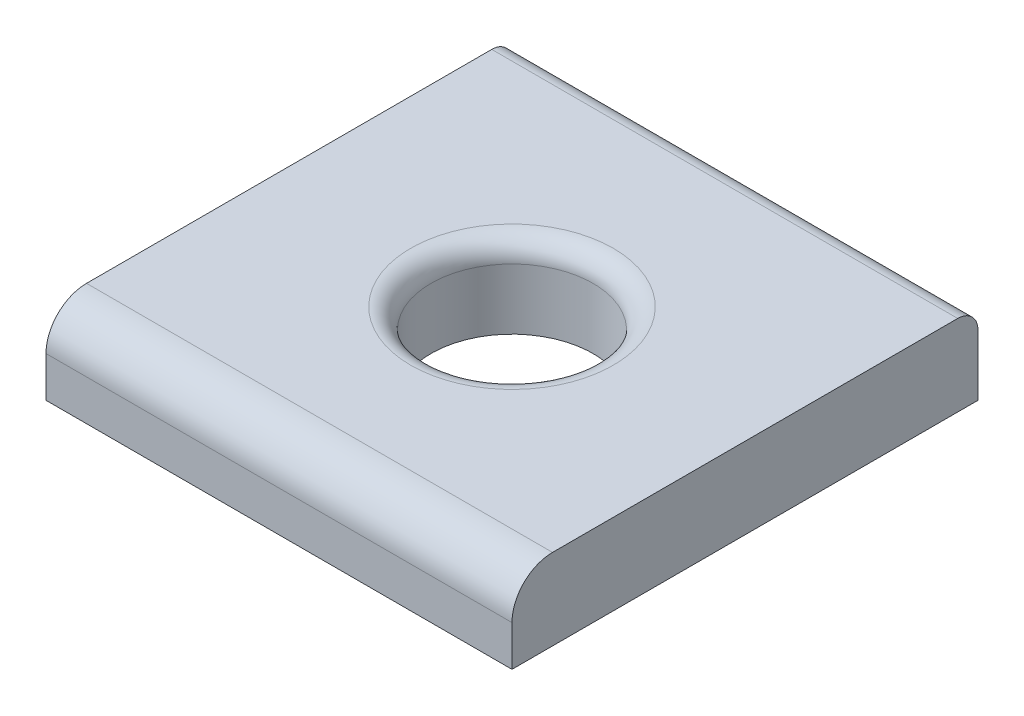
from build123d import *

# Parameters (mm, degrees)
SKETCH1_W           = 11.5
SKETCH1_H           = 11.5
BOSS_EXTRUDE1_DEPTH = 2
SKETCH2_R           = 2
CUT_EXTRUDE1_DEPTH  = 3
FILLET1_R           = 1
FILLET2_R           = 0.5
FILLET3_R           = 0.5


with BuildPart() as part:
    # Sketch1 → Boss-Extrude1 (new body)
    with BuildSketch(Plane(origin=(0, 0, 0), x_dir=(1, 0, 0), z_dir=(0, 1, 0))):
        Rectangle(SKETCH1_W, SKETCH1_H)
    extrude(amount=BOSS_EXTRUDE1_DEPTH)

    # Sketch2 → Cut-Extrude1 (cut, through all)
    with BuildSketch(Plane(origin=(0, 2, 0), x_dir=(1, 0, 0), z_dir=(0, 1, 0))):
        Circle(SKETCH2_R)
    extrude(amount=-CUT_EXTRUDE1_DEPTH, mode=Mode.SUBTRACT)

    # Fillet1
    fillet1_edges = [part.edges().sort_by_distance(p)[0] for p in [
        (0, 2, 5.75),
    ]]
    fillet(fillet1_edges, radius=FILLET1_R)

    # Fillet2
    fillet2_edges = [part.edges().sort_by_distance(p)[0] for p in [
        (0, 2, -5.75),
    ]]
    fillet(fillet2_edges, radius=FILLET2_R)

    # Fillet3
    fillet3_edges = [part.edges().sort_by_distance(p)[0] for p in [
        (-2, 2, 0),
    ]]
    fillet(fillet3_edges, radius=FILLET3_R)


solid = part.part
